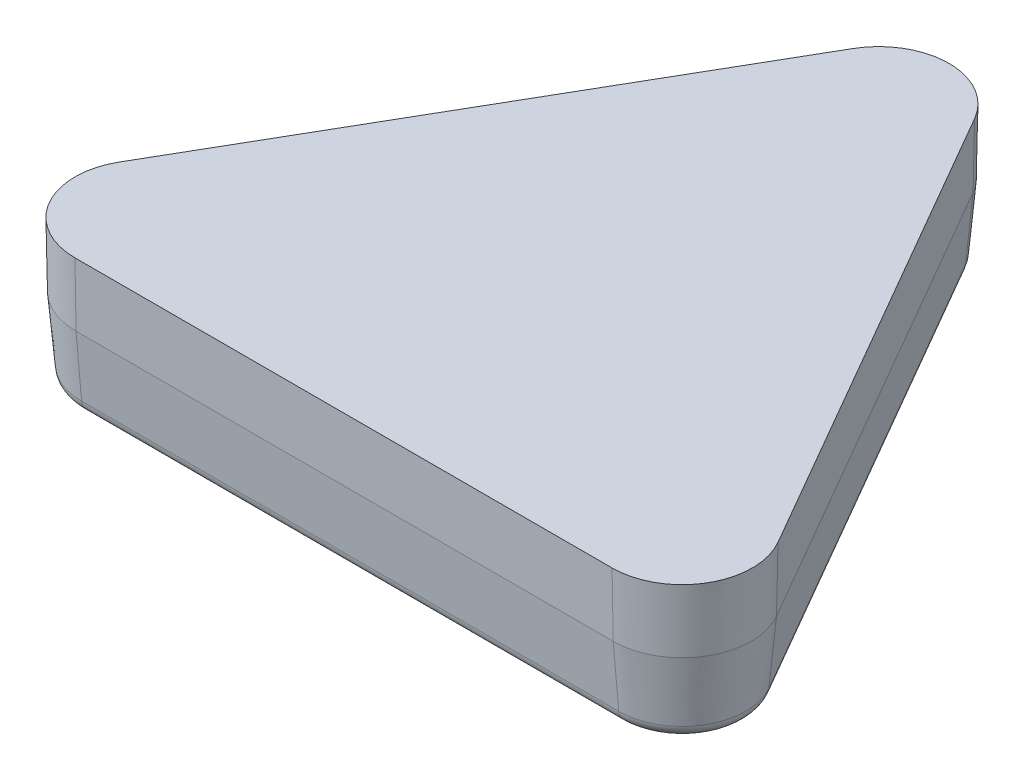
from build123d import *

# Parameters (mm, degrees)
BOSS_EXTRUDE1_DEPTH = 6.35
BOSS_EXTRUDE1_DRAFT = -1
CUT_EXTRUDE3_DEPTH  = 24.909662179
CIRPATTERN3_COUNT   = 24
BOSS_EXTRUDE3_DEPTH = 6.35
BOSS_EXTRUDE3_DRAFT = -1
SKETCH8_OUTSIDE_W   = 45.346
SKETCH8_OUTSIDE_H   = 42.089
CUT_EXTRUDE4_DEPTH  = 24.909662179
CUT_EXTRUDE4_DRAFT  = 5
DRAFT2_ANGLE        = -5
FILLET2_R           = 0.635


with BuildPart() as part:
    # Sketch1 → Boss-Extrude1 (with draft: the straight prism first)
    with BuildSketch(Plane(origin=(0, 0, 0), x_dir=(1, 0, 0), z_dir=(0, 1, 0))):
        with BuildLine():
            Line((-2.749630657, 15.625233333), (-14.906664335, -5.431366667))
            ThreePointArc((-14.906664335, -5.431366667), (-14.906664335, -8.606366667), (-12.157033678, -10.193866667))
            Line((-12.157033678, -10.193866667), (12.157033678, -10.193866667))
            ThreePointArc((12.157033678, -10.193866667), (14.906664335, -8.606366667), (14.906664335, -5.431366667))
            Line((14.906664335, -5.431366667), (2.749630657, 15.625233333))
            ThreePointArc((2.749630657, 15.625233333), (0, 17.212733333), (-2.749630657, 15.625233333))
        make_face()
    extrude(amount=-BOSS_EXTRUDE1_DEPTH)
    # Boss-Extrude1: the draft: its side faces are tilted about the plane it starts from
    boss_extrude1_sides = [part.faces().sort_by_distance(p)[0] for p in [
        (8.828147496, -3.175, -5.096933333),
        (0, -3.175, -17.212733333),
        (-8.828147496, -3.175, -5.096933333),
        (-14.906664335, -3.175, 8.606366667),
        (0, -3.175, 10.193866667),
        (14.906664335, -3.175, 8.606366667),
    ]]
    draft(boss_extrude1_sides, Plane(origin=(0, 0, 0), x_dir=(1, 0, 0), z_dir=(0, 1, 0)), BOSS_EXTRUDE1_DRAFT)

    # Sketch6 → Cut-Extrude3 (cut, through all)
    with BuildSketch(Plane.XY):
        Polygon((0, -2.54), (-6.985, -9.525), (6.985, -9.525), align=None)
    cut_extrude3 = extrude(amount=-CUT_EXTRUDE3_DEPTH, mode=Mode.SUBTRACT)

    # CirPattern3: Cut-Extrude3 ×24 about axis
    cirpattern3_axis = Axis((0, 0, 0), (0, 1, 0))
    for i in range(1, CIRPATTERN3_COUNT):
        add(cut_extrude3.rotate(cirpattern3_axis, i * 360 / CIRPATTERN3_COUNT), mode=Mode.SUBTRACT)


with BuildPart() as boss_extrude3_tool:
    # Sketch7 → Boss-Extrude3 (with draft: the straight prism first)
    with BuildSketch(Plane(origin=(0, 0, 0), x_dir=(1, 0, 0), z_dir=(0, 1, 0))):
        with BuildLine():
            Line((-12.157033678, -10.193866667), (12.157033678, -10.193866667))
            ThreePointArc((12.157033678, -10.193866667), (14.906664335, -8.606366667), (14.906664335, -5.431366667))
            Line((14.906664335, -5.431366667), (2.749630657, 15.625233333))
            ThreePointArc((2.749630657, 15.625233333), (0, 17.212733333), (-2.749630657, 15.625233333))
            Line((-2.749630657, 15.625233333), (-14.906664335, -5.431366667))
            ThreePointArc((-14.906664335, -5.431366667), (-14.906664335, -8.606366667), (-12.157033678, -10.193866667))
        make_face()
        with BuildLine():
            Line((-12.157033678, -8.034866667), (12.157033678, -8.034866667))
            ThreePointArc((12.157033678, -8.034866667), (13.036915488, -7.526866667), (13.036915488, -6.510866667))
            Line((13.036915488, -6.510866667), (0.87988181, 14.545733333))
            ThreePointArc((0.87988181, 14.545733333), (0, 15.053733333), (-0.87988181, 14.545733333))
            Line((-0.87988181, 14.545733333), (-13.036915488, -6.510866667))
            ThreePointArc((-13.036915488, -6.510866667), (-13.036915488, -7.526866667), (-12.157033678, -8.034866667))
        make_face(mode=Mode.SUBTRACT)
    extrude(amount=-BOSS_EXTRUDE3_DEPTH)
    # Boss-Extrude3: the draft: its side faces are tilted about the plane it starts from
    boss_extrude3_sides = [boss_extrude3_tool.faces().sort_by_distance(p)[0] for p in [
        (0, -3.175, 10.193866667),
        (14.906664335, -3.175, 8.606366667),
        (8.828147496, -3.175, -5.096933333),
        (0, -3.175, -17.212733333),
        (-8.828147496, -3.175, -5.096933333),
        (-14.906664335, -3.175, 8.606366667),
        (-13.036915488, -3.175, 7.526866667),
        (-6.958398649, -3.175, -4.017433333),
        (0, -3.175, -15.053733333),
        (6.958398649, -3.175, -4.017433333),
        (13.036915488, -3.175, 7.526866667),
        (0, -3.175, 8.034866667),
    ]]
    draft(boss_extrude3_sides, Plane(origin=(0, 0, 0), x_dir=(1, 0, 0), z_dir=(0, 1, 0)), BOSS_EXTRUDE3_DRAFT)


with BuildPart() as part_1:
    add(part.part)

    # Boss-Extrude3: add boss_extrude3_tool
    add(boss_extrude3_tool.part)


with BuildPart() as cut_extrude4_tool:
    # Sketch8 outside → Cut-Extrude4 (with draft: the straight prism first)
    with BuildSketch(Plane(origin=(0, 0, 0), x_dir=(1, 0, 0), z_dir=(0, 1, 0))):
        with Locations((0, 3.5095)):
            Rectangle(SKETCH8_OUTSIDE_W, SKETCH8_OUTSIDE_H)
        with BuildLine():
            Line((-12.157033678, -10.397066667), (12.157033678, -10.397066667))
            ThreePointArc((12.157033678, -10.397066667), (15.082640697, -8.707966667), (15.082640697, -5.329766667))
            Line((15.082640697, -5.329766667), (2.925607019, 15.726833333))
            ThreePointArc((2.925607019, 15.726833333), (0, 17.415933333), (-2.925607019, 15.726833333))
            Line((-2.925607019, 15.726833333), (-15.082640697, -5.329766667))
            ThreePointArc((-15.082640697, -5.329766667), (-15.082640697, -8.707966667), (-12.157033678, -10.397066667))
        make_face(mode=Mode.SUBTRACT)
    extrude(amount=-CUT_EXTRUDE4_DEPTH)
    # Cut-Extrude4: the draft: its side faces are tilted about the plane it starts from
    cut_extrude4_sides = [cut_extrude4_tool.faces().sort_by_distance(p)[0] for p in [
        (0, -12.45483109, 17.535),
        (22.673, -12.45483109, -3.5095),
        (0, -12.45483109, -24.554),
        (-22.673, -12.45483109, -3.5095),
        (-9.004123858, -12.45483109, -5.198533333),
        (0, -12.45483109, -17.415933333),
        (9.004123858, -12.45483109, -5.198533333),
        (15.082640697, -12.45483109, 8.707966667),
        (0, -12.45483109, 10.397066667),
        (-15.082640697, -12.45483109, 8.707966667),
    ]]
    draft(cut_extrude4_sides, Plane(origin=(0, 0, 0), x_dir=(1, 0, 0), z_dir=(0, 1, 0)), CUT_EXTRUDE4_DRAFT)


with BuildPart() as part_2:
    add(part_1.part)

    # Cut-Extrude4: cut by cut_extrude4_tool
    add(cut_extrude4_tool.part, mode=Mode.SUBTRACT)

    # Draft2
    draft2_faces = [part_2.faces().sort_by_distance(p)[0] for p in [
        (-13.104108463, -4.445, 7.565660548),
        (-7.03077319, -4.787774892, -4.059218794),
        (0, -4.445, -15.131321097),
        (7.03077319, -4.787774892, -4.059218794),
        (13.104108463, -4.445, 7.565660548),
        (0, -4.787774892, 8.118437588),
    ]]
    draft(draft2_faces, Plane(origin=(-12.157033678, 0, 7.018866667), x_dir=(0, 0, 1), z_dir=(0, 1, 0)), DRAFT2_ANGLE)

    # Fillet2
    fillet2_edges = [part_2.edges().sort_by_distance(p)[0] for p in [
        (-7.439521672, -6.35, -4.29520984),
        (-13.518038511, -6.35, 7.804643173),
        (0, -6.35, 8.59041968),
        (13.518038511, -6.35, 7.804643173),
        (7.439521672, -6.35, -4.29520984),
        (0, -6.35, -15.609286347),
        (-8.523000835, -6.35, -4.920756827),
        (-14.601517675, -6.35, 8.43019016),
        (0, -6.35, 9.841513653),
        (14.601517675, -6.35, 8.43019016),
        (8.523000835, -6.35, -4.920756827),
        (0, -6.35, -16.86038032),
    ]]
    fillet(fillet2_edges, radius=FILLET2_R)


solid = part_2.part
